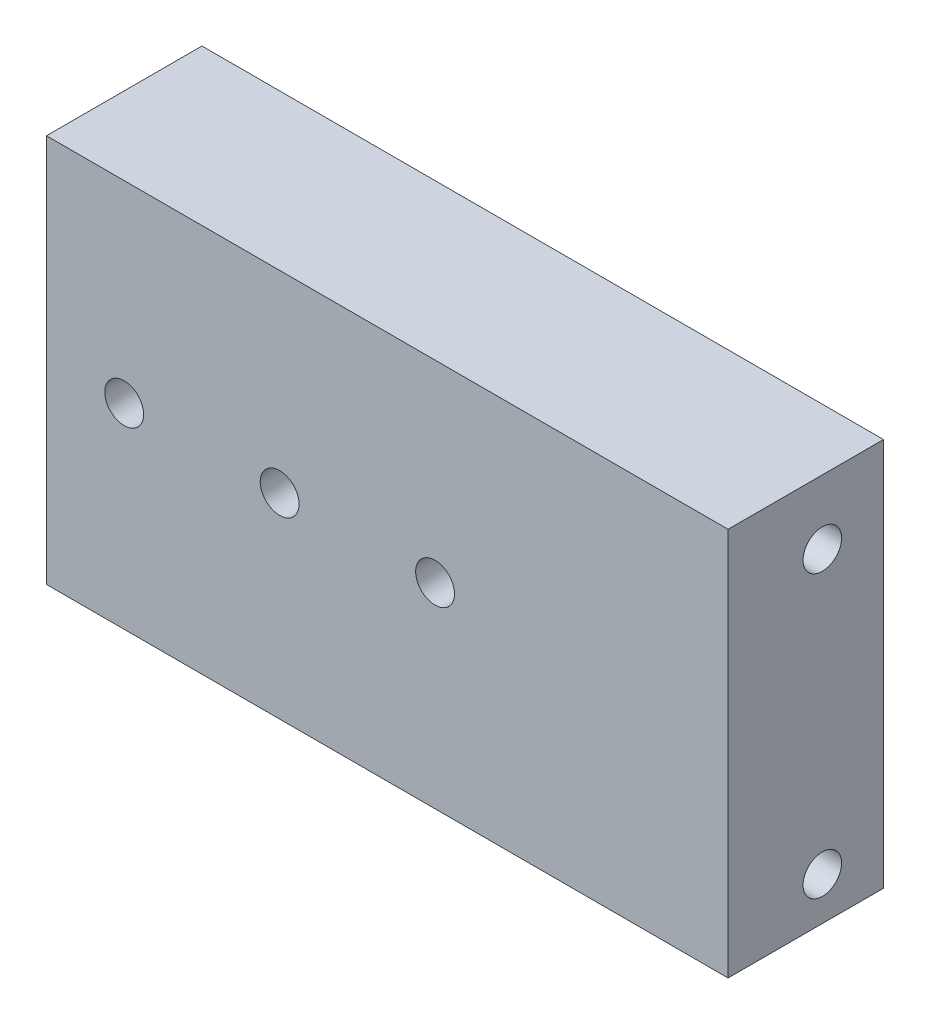
from build123d import *

# Parameters (mm, degrees)
SKETCH1_W                   = 25.4
SKETCH1_H                   = 63.5
BOSS_EXTRUDE1_DEPTH         = 111.37596
F_1_4_0_25_DIAMETER_HOLE1_D = 6.35
F_6_0MM_DOWEL_HOLE1_D       = 6.3
F_6_0MM_DOWEL_HOLE1_DEPTH   = 9.0000074
F_6_0MM_DOWEL_HOLE1_TIP     = 1.89271095


with BuildPart() as part:
    # Sketch1 → Boss-Extrude1 (new body)
    with BuildSketch(Plane(origin=(0, 0, 0), x_dir=(0, 0, -1), z_dir=(1, 0, 0))):
        with Locations((12.7, 31.75)):
            Rectangle(SKETCH1_W, SKETCH1_H)
    extrude(amount=-BOSS_EXTRUDE1_DEPTH)

    # 1/4 (0.25) Diameter Hole1 (through all)
    with Locations(Plane.XY):
        with Locations((-98.67596, 32), (-47.87596, 32), (-73.27596, 32)):
            Hole(F_1_4_0_25_DIAMETER_HOLE1_D / 2)

    # Ø6.0mm Dowel Hole1
    with Locations(Plane(origin=(0, 0, 0), x_dir=(0, 0, -1), z_dir=(1, 0, 0))):
        with Locations((15.4, 7), (15.4, 53)):
            Hole(F_6_0MM_DOWEL_HOLE1_D / 2, depth=F_6_0MM_DOWEL_HOLE1_DEPTH)
            with Locations((0, 0, -(F_6_0MM_DOWEL_HOLE1_DEPTH + F_6_0MM_DOWEL_HOLE1_TIP / 2))):  # 118° drill point
                Cone(0, F_6_0MM_DOWEL_HOLE1_D / 2, F_6_0MM_DOWEL_HOLE1_TIP, mode=Mode.SUBTRACT)


solid = part.part
